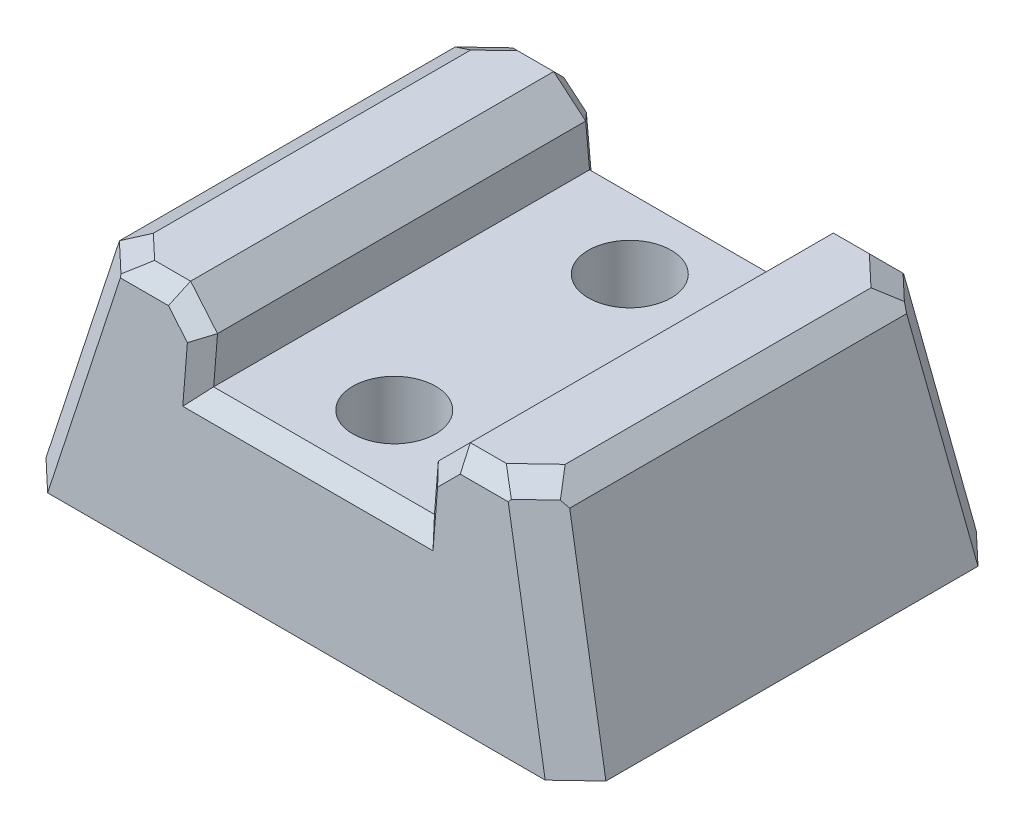
from build123d import *
from OCP.BRepFilletAPI import BRepFilletAPI_MakeChamfer

# Parameters (mm, degrees)
BOSS_EXTRUDE1_DEPTH       = 33.86758938
F_1_4_CLEARANCE_HOLE1_D   = 7.14248
DRAFT1_ANGLE              = 15
DRAFT2_ANGLE              = 15
DRAFT3_ANGLE              = 5
DRAFT4_ANGLE              = 5
CHAMFER1_SIZE             = 2.54
CHAMFER1_SIZE2            = 2.599295174
CHAMFER2_SIZE             = 1.27
CHAMFER2_SIZE2            = 1.356155551
CHAMFER2_SIZE2_2          = 1.397079842
CHAMFER2_SIZE2_3          = 1.796051224
CHAMFER2_SIZE2_4          = 1.739452222
HOLE1_AT_2_COUNT          = 2
HOLE1_AT_2_PITCH          = 24.154432116
F_8_CLEARANCE_HOLE1_D     = 4.9149
F_8_CLEARANCE_HOLE1_DEPTH = 9.525
F_8_CLEARANCE_HOLE1_TIP   = 1.476584928


with BuildPart() as part:
    # Sketch1 → Boss-Extrude1 (new body)
    with BuildSketch(Plane.XY):
        Polygon((133.529465969, -12.7), (114.479465969, -12.7), (114.479465969, -8.89), (111.939465969, -6.35), (107.494465969, -6.35), (104.954465969, -6.35), (104.954465969, -25.4), (143.054465969, -25.4), (143.054465969, -6.35), (140.514465969, -6.35), (136.069465969, -6.35), (133.529465969, -8.89), align=None)
    extrude(amount=-BOSS_EXTRUDE1_DEPTH)

    # 1/4 Clearance Hole1 (through all)
    with Locations(Plane(origin=(0, -12.7, 0), x_dir=(1, 0, 0), z_dir=(0, 1, 0))):
        with Locations((124.004465969, 6.77379469), (124.004465969, 27.09379469)):
            Hole(F_1_4_CLEARANCE_HOLE1_D / 2)

    # Draft1
    draft1_faces = [part.faces().sort_by_distance(p)[0] for p in [
        (143.054465969, -15.875, -16.93379469),
    ]]
    draft(draft1_faces, Plane(origin=(140.514465969, -6.35, -76.464684351), x_dir=(1, 0, 0), z_dir=(0, 1, 0)), DRAFT1_ANGLE)

    # Draft2
    draft2_faces = [part.faces().sort_by_distance(p)[0] for p in [
        (104.954465969, -15.875, -16.93379469),
    ]]
    draft(draft2_faces, Plane(origin=(140.514465969, -6.35, -76.464684351), x_dir=(1, 0, 0), z_dir=(0, 1, 0)), DRAFT2_ANGLE)

    # Draft3
    draft3_faces = [part.faces().sort_by_distance(p)[0] for p in [
        (124.004465969, -17.503560526, 0),
    ]]
    draft(draft3_faces, Plane(origin=(140.514465969, -6.35, -76.464684351), x_dir=(1, 0, 0), z_dir=(0, 1, 0)), DRAFT3_ANGLE)

    # Draft4
    draft4_faces = [part.faces().sort_by_distance(p)[0] for p in [
        (124.004465969, -17.503560526, -33.86758938),
    ]]
    draft(draft4_faces, Plane(origin=(140.514465969, -6.35, -76.464684351), x_dir=(1, 0, 0), z_dir=(0, 1, 0)), DRAFT4_ANGLE)

    # Chamfer1: one chamfer whose edges measure the first distance from different faces: ONE call of the kernel's chamfer builder (chamfer() names one face for all edges)
    chamfer1_edges_1 = [part.edges().sort_by_distance(p)[0] for p in [
        (145.606682027, -15.875, 0.83332952),
        (145.606682027, -15.875, -34.7009189),
    ]]
    chamfer1_side_1 = [part.faces().sort_by_distance(p)[0] for p in [
        (145.646584132, -16.023916684, -16.93379469),
    ]]
    chamfer1_edges_2 = [part.edges().sort_by_distance(p)[0] for p in [
        (102.402249911, -15.875, 0.83332952),
        (102.402249911, -15.875, -34.7009189),
    ]]
    chamfer1_side_2 = [part.faces().sort_by_distance(p)[0] for p in [
        (102.362347806, -16.023916684, -16.93379469),
    ]]
    chamfer1 = BRepFilletAPI_MakeChamfer(part.part.solid().wrapped)
    for e in chamfer1_edges_1:
        chamfer1.Add(CHAMFER1_SIZE, CHAMFER1_SIZE2, e.wrapped, chamfer1_side_1[0].wrapped)  # the first distance lies on this face
    for e in chamfer1_edges_2:
        chamfer1.Add(CHAMFER1_SIZE, CHAMFER1_SIZE2, e.wrapped, chamfer1_side_2[0].wrapped)  # the first distance lies on this face
    add(Compound.cast(chamfer1.Shape()), mode=Mode.REPLACE)

    # Chamfer2: one chamfer whose edges measure the first distance from different faces: ONE call of the kernel's chamfer builder (chamfer() names one face for all edges)
    chamfer2_edges_1 = [part.edges().sort_by_distance(p)[0] for p in [
        (134.799465969, -7.62, 0.111110603),
        (134.799465969, -7.62, -33.978699983),
    ]]
    chamfer2_side_1 = [part.faces().sort_by_distance(p)[0] for p in [
        (134.796706387, -7.622759582, -16.93379469),
    ]]
    chamfer2_edges_2 = [part.edges().sort_by_distance(p)[0] for p in [
        (109.792117792, -6.35, 0),
        (109.792117792, -6.35, -33.86758938),
    ]]
    chamfer2_side_2 = [part.faces().sort_by_distance(p)[0] for p in [
        (108.524459453, -6.35, -16.93379469),
    ]]
    chamfer2_edges_3 = [part.edges().sort_by_distance(p)[0] for p in [
        (113.209465969, -7.62, 0.111110603),
        (113.209465969, -7.62, -33.978699983),
    ]]
    chamfer2_side_3 = [part.faces().sort_by_distance(p)[0] for p in [
        (113.212225552, -7.622759582, -16.93379469),
    ]]
    chamfer2_edges_4 = [part.edges().sort_by_distance(p)[0] for p in [
        (114.479465969, -10.795, 0.388887109),
        (133.529465969, -10.795, 0.388887109),
        (114.479465969, -10.795, -34.256476489),
        (133.529465969, -10.795, -34.256476489),
    ]]
    chamfer2_edges_5 = [part.edges().sort_by_distance(p)[0] for p in [
        (124.004465969, -12.7, 0.555553013),
        (124.004465969, -12.7, -34.423142393),
    ]]
    chamfer2_side_5 = [part.faces().sort_by_distance(p)[0] for p in [
        (124.004465969, -12.7, -16.93379469),
    ]]
    chamfer2_edges_6 = [part.edges().sort_by_distance(p)[0] for p in [
        (138.216814146, -6.35, -33.86758938),
        (138.216814146, -6.35, 0),
    ]]
    chamfer2_side_6 = [part.faces().sort_by_distance(p)[0] for p in [
        (139.484472486, -6.35, -16.93379469),
    ]]
    chamfer2_edges_7 = [part.edges().sort_by_distance(p)[0] for p in [
        (104.954465969, -6.35, -16.93379469),
    ]]
    chamfer2_side_7 = [part.faces().sort_by_distance(p)[0] for p in [
        (102.355664133, -16.048860491, -16.93379469),
    ]]
    chamfer2_edges_8 = [part.edges().sort_by_distance(p)[0] for p in [
        (106.299617792, -6.35, -1.274526802),
    ]]
    chamfer2_side_8 = [part.faces().sort_by_distance(p)[0] for p in [
        (103.747401735, -15.875, -0.441197282),
    ]]
    chamfer2_edges_9 = [part.edges().sort_by_distance(p)[0] for p in [
        (106.299617792, -6.35, -32.593062578),
    ]]
    chamfer2_side_9 = [part.faces().sort_by_distance(p)[0] for p in [
        (103.747401735, -15.875, -33.426392098),
    ]]
    chamfer2_edges_10 = [part.edges().sort_by_distance(p)[0] for p in [
        (143.054465969, -6.35, -16.93379469),
    ]]
    chamfer2_side_10 = [part.faces().sort_by_distance(p)[0] for p in [
        (139.484472486, -6.35, -16.93379469),
    ]]
    chamfer2_edges_11 = [part.edges().sort_by_distance(p)[0] for p in [
        (141.709314146, -6.35, -1.274526802),
    ]]
    chamfer2_side_11 = [part.faces().sort_by_distance(p)[0] for p in [
        (144.261530204, -15.875, -0.441197282),
    ]]
    chamfer2_edges_12 = [part.edges().sort_by_distance(p)[0] for p in [
        (141.709314146, -6.35, -32.593062578),
    ]]
    chamfer2_side_12 = [part.faces().sort_by_distance(p)[0] for p in [
        (144.261530204, -15.875, -33.426392098),
    ]]
    chamfer2 = BRepFilletAPI_MakeChamfer(part.part.solid().wrapped)
    for e in chamfer2_edges_1:
        chamfer2.Add(CHAMFER2_SIZE, CHAMFER2_SIZE2, e.wrapped, chamfer2_side_1[0].wrapped)  # the first distance lies on this face
    for e in chamfer2_edges_2:
        chamfer2.Add(CHAMFER2_SIZE, CHAMFER2_SIZE2_2, e.wrapped, chamfer2_side_2[0].wrapped)  # the first distance lies on this face
    for e in chamfer2_edges_3:
        chamfer2.Add(CHAMFER2_SIZE, CHAMFER2_SIZE2, e.wrapped, chamfer2_side_3[0].wrapped)  # the first distance lies on this face
    for e in chamfer2_edges_4:
        chamfer2.Add(CHAMFER2_SIZE, e.wrapped)
    for e in chamfer2_edges_5:
        chamfer2.Add(CHAMFER2_SIZE, CHAMFER2_SIZE2_2, e.wrapped, chamfer2_side_5[0].wrapped)  # the first distance lies on this face
    for e in chamfer2_edges_6:
        chamfer2.Add(CHAMFER2_SIZE, CHAMFER2_SIZE2_2, e.wrapped, chamfer2_side_6[0].wrapped)  # the first distance lies on this face
    for e in chamfer2_edges_7:
        chamfer2.Add(CHAMFER2_SIZE, CHAMFER2_SIZE2_3, e.wrapped, chamfer2_side_7[0].wrapped)  # the first distance lies on this face
    for e in chamfer2_edges_8:
        chamfer2.Add(CHAMFER2_SIZE, CHAMFER2_SIZE2_4, e.wrapped, chamfer2_side_8[0].wrapped)  # the first distance lies on this face
    for e in chamfer2_edges_9:
        chamfer2.Add(CHAMFER2_SIZE, CHAMFER2_SIZE2_4, e.wrapped, chamfer2_side_9[0].wrapped)  # the first distance lies on this face
    for e in chamfer2_edges_10:
        chamfer2.Add(CHAMFER2_SIZE, CHAMFER2_SIZE2_3, e.wrapped, chamfer2_side_10[0].wrapped)  # the first distance lies on this face
    for e in chamfer2_edges_11:
        chamfer2.Add(CHAMFER2_SIZE, CHAMFER2_SIZE2_4, e.wrapped, chamfer2_side_11[0].wrapped)  # the first distance lies on this face
    for e in chamfer2_edges_12:
        chamfer2.Add(CHAMFER2_SIZE, CHAMFER2_SIZE2_4, e.wrapped, chamfer2_side_12[0].wrapped)  # the first distance lies on this face
    add(Compound.cast(chamfer2.Shape()), mode=Mode.REPLACE)

    # Sketch5 → Hole1 (revolve, cut)
    with BuildSketch(Plane(origin=(111.927249911, -25.4, -16.93379469), x_dir=(0, 0, -1), z_dir=(1, 0, 0))):
        Polygon((0, 0), (0, 4.699), (2.8702, 4.699), (2.9972, 0), align=None)
    hole1 = revolve(axis=Axis((111.927249911, 84.6, -16.93379469), (0, -1, 0)), mode=Mode.SUBTRACT)

    # Hole1 at 2: Hole1 ×2
    with Locations(*[(i * HOLE1_AT_2_PITCH, 0, 0) for i in range(1, HOLE1_AT_2_COUNT)]):
        add(hole1, mode=Mode.SUBTRACT)

    # #8 Clearance Hole1
    with Locations(Plane(origin=(0, -25.4, 0), x_dir=(-1, 0, 0), z_dir=(0, -1, 0))):
        with Locations((-136.081682027, 16.93379469), (-111.927249911, 16.93379469)):
            Hole(F_8_CLEARANCE_HOLE1_D / 2, depth=F_8_CLEARANCE_HOLE1_DEPTH)
            with Locations((0, 0, -(F_8_CLEARANCE_HOLE1_DEPTH + F_8_CLEARANCE_HOLE1_TIP / 2))):  # 118° drill point
                Cone(0, F_8_CLEARANCE_HOLE1_D / 2, F_8_CLEARANCE_HOLE1_TIP, mode=Mode.SUBTRACT)


solid = part.part
